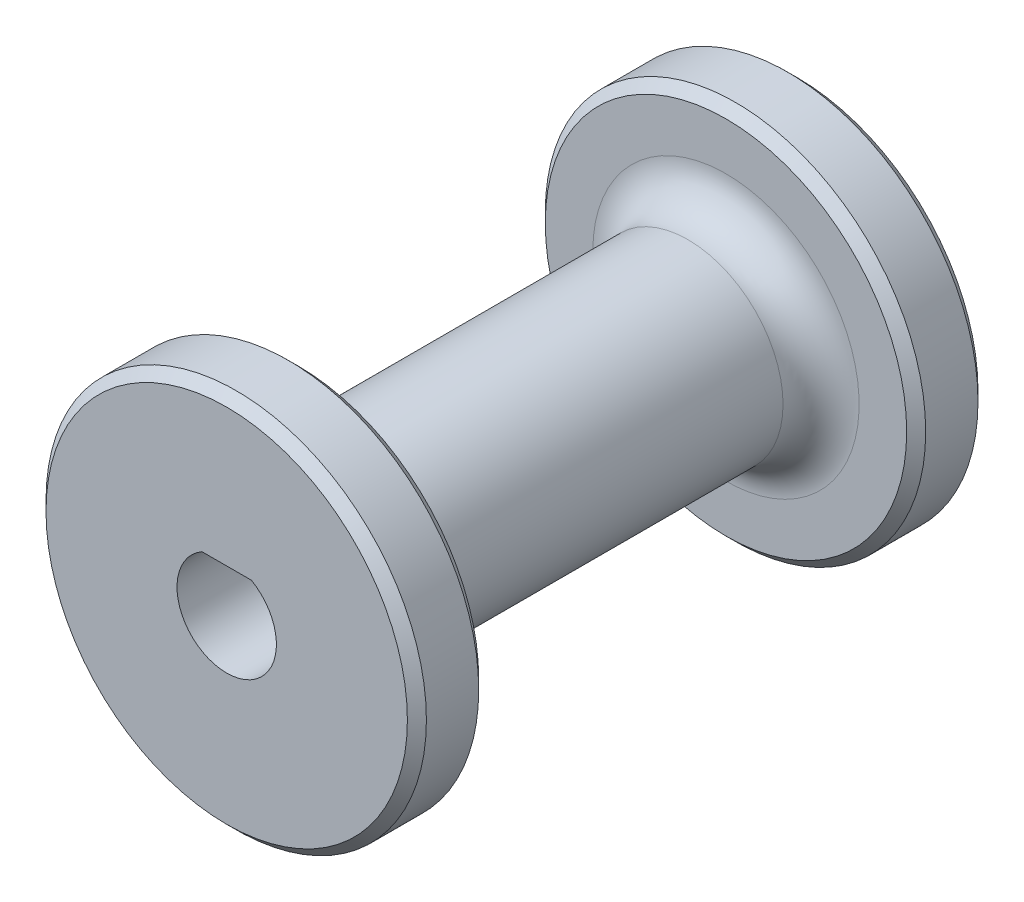
from build123d import *

# Parameters (mm, degrees)
SKETCH1_R                = 6.35
SKETCH1_R_2              = 3.317499969
BOSS_EXTRUDE1_DEPTH      = 14.2875
BOSS_EXTRUDE1_DEPTH_BACK = 14.2875
SKETCH2_R                = 12.7
SKETCH2_R_2              = 6.35
SKETCH2_R_3              = 3.317499969
BOSS_EXTRUDE3_DEPTH      = 4.7625
SKETCH3_R                = 3.317499969
BOSS_EXTRUDE4_DEPTH      = 24.13
FILLET1_R                = 2.54
CHAMFER1_SIZE            = 0.635
BOSS_EXTRUDE5_REACH      = 44.121


with BuildPart() as part:
    # Sketch1 → Boss-Extrude1 (new, two sides)
    with BuildSketch(Plane.XY) as boss_extrude1_sk:
        Circle(SKETCH1_R)
        Circle(SKETCH1_R_2, mode=Mode.SUBTRACT)
    extrude(amount=BOSS_EXTRUDE1_DEPTH)
    extrude(boss_extrude1_sk.sketch, amount=-BOSS_EXTRUDE1_DEPTH_BACK)

    # Sketch2 → Boss-Extrude3 (add)
    with BuildSketch(Plane(origin=(0, 0, -14.2875), x_dir=(-1, 0, 0), z_dir=(0, 0, -1))):
        with Locations(Location((0, 0, 0), (0, 0, 180))):
            Circle(SKETCH2_R)
        with Locations(Location((0, 0, 0), (0, 0, 180))):
            Circle(SKETCH2_R_2, mode=Mode.SUBTRACT)
        with Locations(Location((0, 0, 0), (0, 0, 180))):
            Circle(SKETCH2_R_2)
        with Locations(Location((0, 0, 0), (0, 0, 180))):
            Circle(SKETCH2_R_3, mode=Mode.SUBTRACT)
    boss_extrude3 = extrude(amount=BOSS_EXTRUDE3_DEPTH)

    # Mirror1: Boss-Extrude3 across plane
    add(boss_extrude3.mirror(Plane.XY))

    # Sketch3 → Boss-Extrude4 (add)
    with BuildSketch(Plane(origin=(0, 0, -19.05), x_dir=(-1, 0, 0), z_dir=(0, 0, -1))):
        Circle(SKETCH3_R)
    extrude(amount=-BOSS_EXTRUDE4_DEPTH)

    # Fillet1
    fillet1_edges = [part.edges().sort_by_distance(p)[0] for p in [
        (-6.35, 0, -14.2875),
        (-6.35, 0, 14.2875),
    ]]
    fillet(fillet1_edges, radius=FILLET1_R)

    # Chamfer1
    chamfer1_edges = [part.edges().sort_by_distance(p)[0] for p in [
        (-12.7, 0, -14.2875),
        (-12.7, 0, -19.05),
        (-12.7, 0, 19.05),
        (-12.7, 0, 14.2875),
    ]]
    chamfer(chamfer1_edges, length=CHAMFER1_SIZE)

    # Sketch4 → Boss-Extrude5 (add, up to next)
    with BuildSketch(Plane.XY.offset(19.05), mode=Mode.PRIVATE) as boss_extrude5_sk1:
        with BuildLine():
            ThreePointArc((1.651, 2.87749979), (0, 3.317499969), (-1.651, 2.87749979))
            Line((-1.651, 2.87749979), (1.651, 2.87749979))
        make_face()
    boss_extrude5_tool1 = extrude(boss_extrude5_sk1.sketch, amount=-BOSS_EXTRUDE5_REACH, mode=Mode.PRIVATE) - part.part
    add(boss_extrude5_tool1.solids().sort_by_distance((0, 3.05454, 19.05))[0])


solid = part.part
